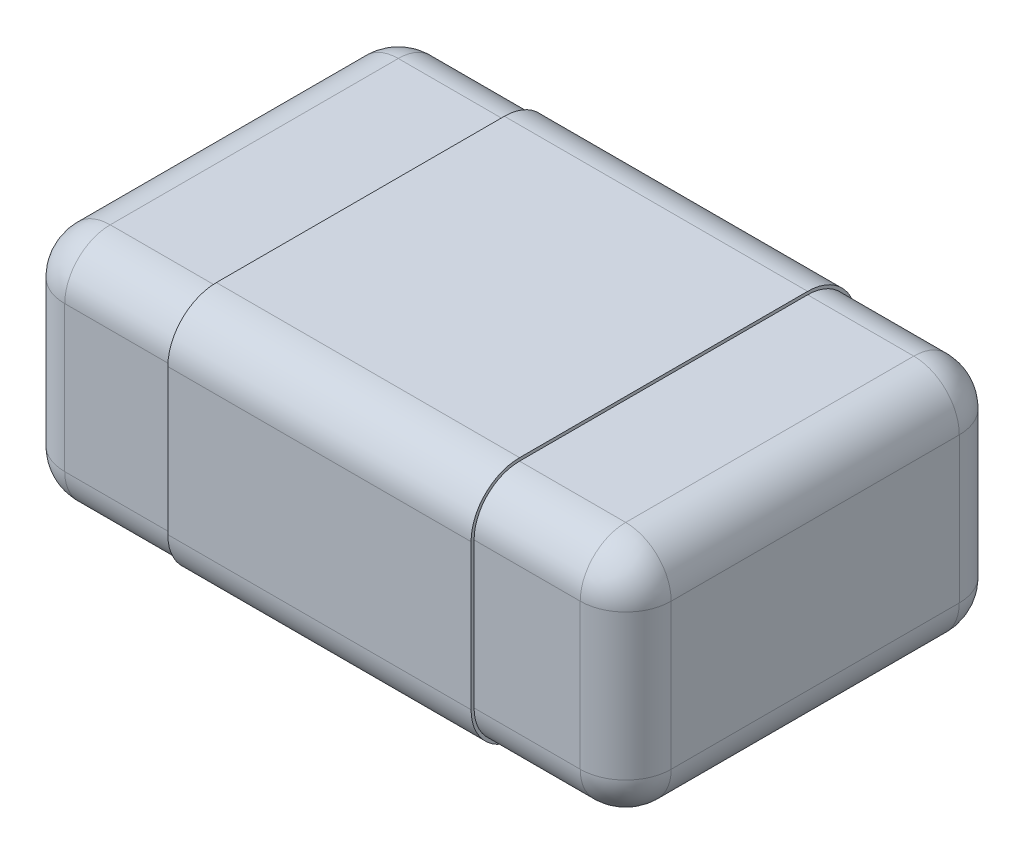
from build123d import *

# Parameters (mm, degrees)
ESBO_O1_W                     = 2
ESBO_O1_H                     = 1.25
RESSALTO_EXTRUS_O1_DEPTH      = 0.78
FILETE1_R                     = 0.15
RESSALTO_EXTRUS_O4_DEPTH      = 0.5
RESSALTO_EXTRUS_O4_DEPTH_BACK = 0.5


with BuildPart() as part:
    # Esboço1 → Ressalto-extrusão1 (new body)
    with BuildSketch(Plane(origin=(0, 0, 0), x_dir=(1, 0, 0), z_dir=(0, 1, 0))):
        Rectangle(ESBO_O1_W, ESBO_O1_H)
    extrude(amount=-RESSALTO_EXTRUS_O1_DEPTH)

    # Filete1
    filete1_edges = [part.edges().sort_by_distance(p)[0] for p in [
        (1, -0.78, 0),
        (0, -0.78, -0.625),
        (-1, -0.78, 0),
        (0, 0, -0.625),
        (1, 0, 0),
        (0, 0, 0.625),
        (-1, 0, 0),
        (0, -0.78, 0.625),
        (-1, -0.39, -0.625),
        (1, -0.39, -0.625),
        (1, -0.39, 0.625),
        (-1, -0.39, 0.625),
    ]]
    fillet(filete1_edges, radius=FILETE1_R)

    # Esboço4 → Ressalto-extrusão4 (add, two sides)
    with BuildSketch(Plane(origin=(0, 0, 0), x_dir=(0, 0, -1), z_dir=(1, 0, 0))) as ressalto_extrus_o4_sk:
        with BuildLine():
            Line((0.635, -0.63), (0.635, -0.15))
            ThreePointArc((0.635, -0.15), (0.588137085, -0.036862915), (0.475, 0.01))
            Line((0.475, 0.01), (-0.475, 0.01))
            ThreePointArc((-0.475, 0.01), (-0.588137085, -0.036862915), (-0.635, -0.15))
            Line((-0.635, -0.15), (-0.635, -0.63))
            ThreePointArc((-0.635, -0.63), (-0.588137085, -0.743137085), (-0.475, -0.79))
            Line((-0.475, -0.79), (0.475, -0.79))
            ThreePointArc((0.475, -0.79), (0.588137085, -0.743137085), (0.635, -0.63))
        make_face()
        with BuildLine():
            Line((0.625, -0.63), (0.625, -0.15))
            ThreePointArc((0.625, -0.15), (0.581066017, -0.043933983), (0.475, 0))
            Line((0.475, 0), (-0.475, 0))
            ThreePointArc((-0.475, 0), (-0.581066017, -0.043933983), (-0.625, -0.15))
            Line((-0.625, -0.15), (-0.625, -0.63))
            ThreePointArc((-0.625, -0.63), (-0.581066017, -0.736066017), (-0.475, -0.78))
            Line((-0.475, -0.78), (0.475, -0.78))
            ThreePointArc((0.475, -0.78), (0.581066017, -0.736066017), (0.625, -0.63))
        make_face(mode=Mode.SUBTRACT)
    extrude(amount=RESSALTO_EXTRUS_O4_DEPTH)
    extrude(ressalto_extrus_o4_sk.sketch, amount=-RESSALTO_EXTRUS_O4_DEPTH_BACK)


solid = part.part
